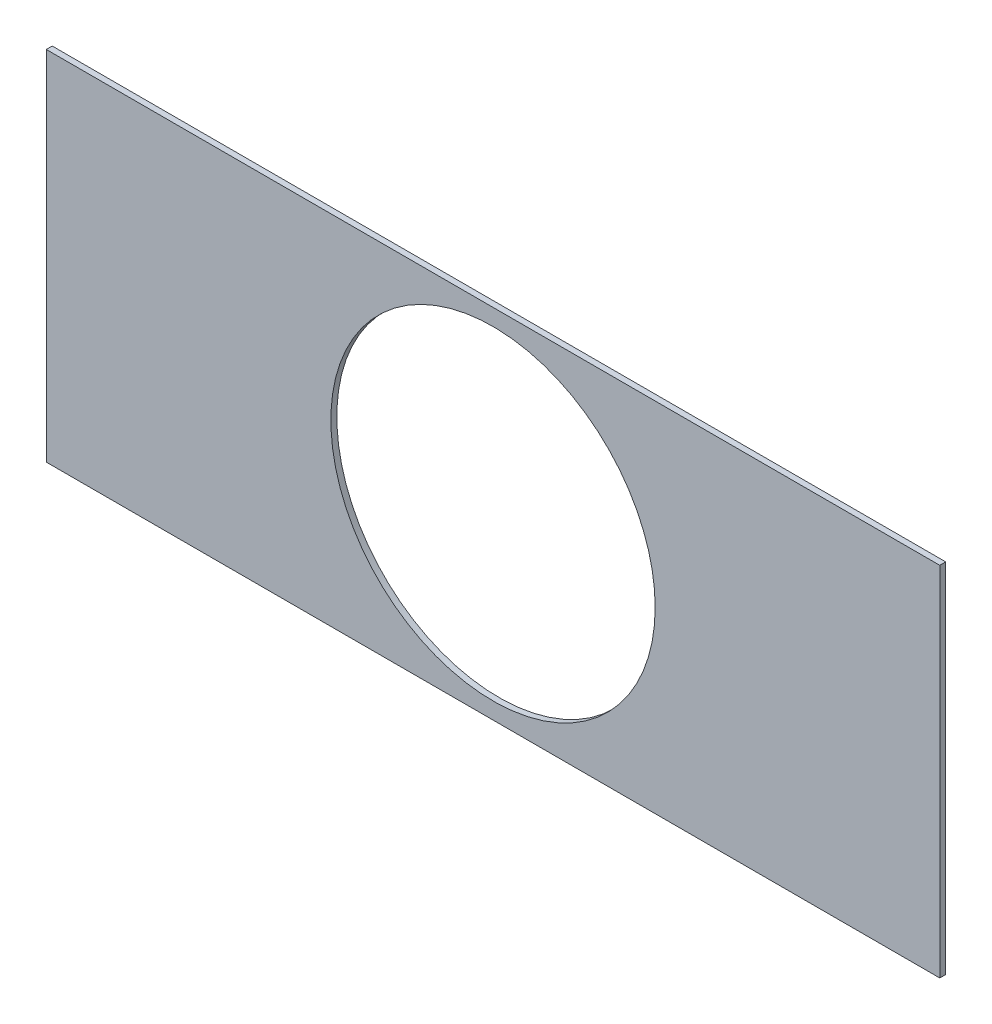
from build123d import *

# Parameters (mm, degrees)
SKETCH1_W           = 300
SKETCH1_H           = 120
SKETCH1_R           = 54.450069984
BOSS_EXTRUDE1_DEPTH = 2


with BuildPart() as part:
    # Sketch1 → Boss-Extrude1 (new body)
    with BuildSketch(Plane.XY):
        with Locations((0, 23.299180328)):
            Rectangle(SKETCH1_W, SKETCH1_H)
        with Locations((0, 23.299180328)):
            Circle(SKETCH1_R, mode=Mode.SUBTRACT)
    extrude(amount=BOSS_EXTRUDE1_DEPTH)


solid = part.part
